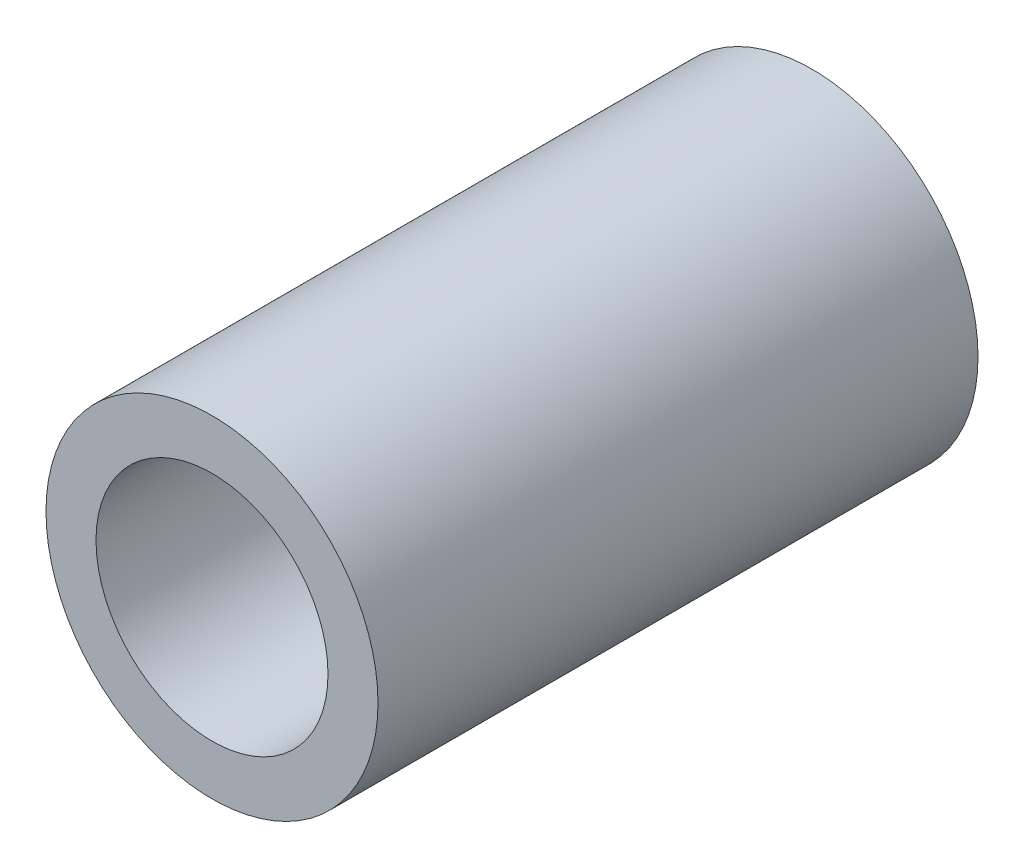
from build123d import *

# Parameters (mm, degrees)
SKETCH1_R           = 10.541
SKETCH1_R_2         = 7.366
BOSS_EXTRUDE1_DEPTH = 38.1


with BuildPart() as part:
    # Sketch1 → Boss-Extrude1 (new body)
    with BuildSketch(Plane.XY):
        Circle(SKETCH1_R)
        Circle(SKETCH1_R_2, mode=Mode.SUBTRACT)
    extrude(amount=BOSS_EXTRUDE1_DEPTH)


solid = part.part
